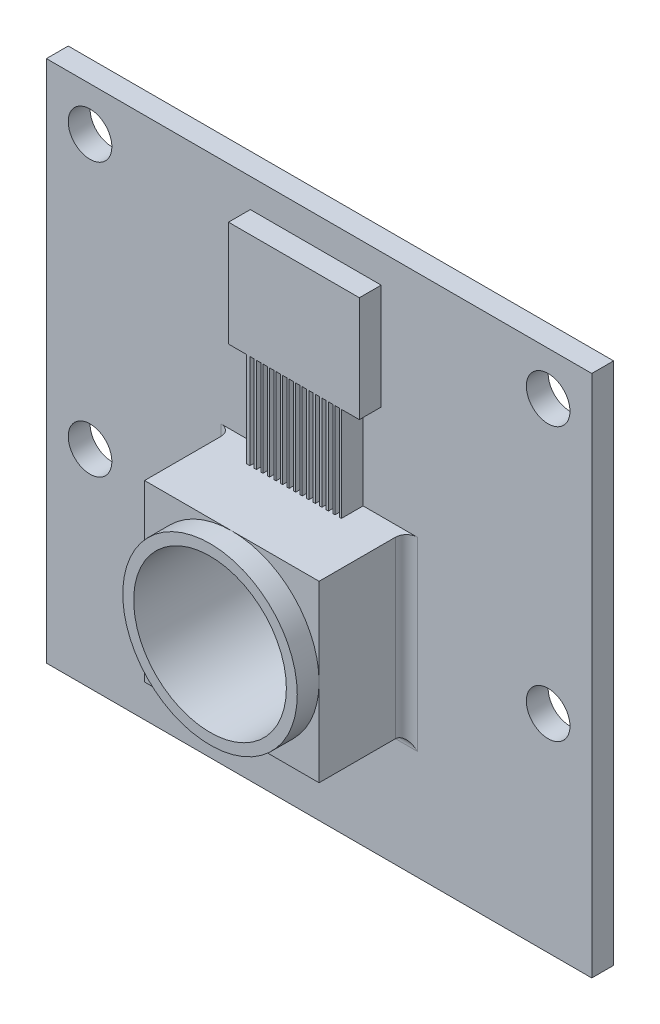
from build123d import *

# Parameters (mm, degrees)
SKETCH1_W           = 25
SKETCH1_H           = 24
SKETCH1_R           = 1
BOSS_EXTRUDE1_DEPTH = 1
SKETCH2_W           = 8
SKETCH2_H           = 8
BOSS_EXTRUDE2_DEPTH = 4
SKETCH3_R           = 4
BOSS_EXTRUDE3_DEPTH = 1
FILLET2_R           = 0.5
SKETCH4_W           = 16
SKETCH4_H           = 5
BOSS_EXTRUDE4_DEPTH = 2
FILLET3_R           = 0.5
SKETCH5_R           = 3.5
CUT_EXTRUDE1_DEPTH  = 6
BOSS_EXTRUDE5_DEPTH = 1
SKETCH7_W           = 0.2
SKETCH7_H           = 4.34
CUT_EXTRUDE2_DEPTH  = 1
LPATTERN1_COUNT     = 14
LPATTERN1_PITCH     = 0.3


with BuildPart() as part:
    # Sketch1 → Boss-Extrude1 (new body)
    with BuildSketch(Plane.XY):
        Rectangle(SKETCH1_W, SKETCH1_H)
        with Locations((10.5, 10)):
            Circle(SKETCH1_R, mode=Mode.SUBTRACT)
        with Locations((-10.5, 10)):
            Circle(SKETCH1_R, mode=Mode.SUBTRACT)
        with Locations((-10.5, -2.5)):
            Circle(SKETCH1_R, mode=Mode.SUBTRACT)
        with Locations((10.5, -2.5)):
            Circle(SKETCH1_R, mode=Mode.SUBTRACT)
    extrude(amount=BOSS_EXTRUDE1_DEPTH)

    # Sketch2 → Boss-Extrude2 (add)
    with BuildSketch(Plane.XY.offset(1)):
        with Locations((0, -2.5)):
            Rectangle(SKETCH2_W, SKETCH2_H)
    extrude(amount=BOSS_EXTRUDE2_DEPTH)

    # Sketch3 → Boss-Extrude3 (add)
    with BuildSketch(Plane.XY.offset(5)):
        with Locations((0, -2.5)):
            Circle(SKETCH3_R)
    extrude(amount=BOSS_EXTRUDE3_DEPTH)

    # Fillet2
    fillet2_edges = [part.edges().sort_by_distance(p)[0] for p in [
        (4, -2.5, 1),
        (-4, -2.5, 1),
        (0, -6.5, 1),
    ]]
    fillet(fillet2_edges, radius=FILLET2_R)

    # Sketch4 → Boss-Extrude4 (add)
    with BuildSketch(Plane(origin=(0, 0, 0), x_dir=(-1, 0, 0), z_dir=(0, 0, -1))):
        with Locations((0, -7.5)):
            Rectangle(SKETCH4_W, SKETCH4_H)
    extrude(amount=BOSS_EXTRUDE4_DEPTH)

    # Fillet3
    fillet3_edges = [part.edges().sort_by_distance(p)[0] for p in [
        (-8, -7.5, 0),
        (-8, -10, -1),
        (0, -5, 0),
        (-8, -5, -1),
        (8, -7.5, 0),
        (8, -5, -1),
        (0, -10, 0),
        (8, -10, -1),
        (-8, -7.5, -2),
        (0, -5, -2),
        (8, -7.5, -2),
        (0, -10, -2),
    ]]
    fillet(fillet3_edges, radius=FILLET3_R)

    # Sketch5 → Cut-Extrude1 (cut)
    with BuildSketch(Plane.XY.offset(6)):
        with Locations((0, -2.5)):
            Circle(SKETCH5_R)
    extrude(amount=-CUT_EXTRUDE1_DEPTH, mode=Mode.SUBTRACT)

    # Sketch6 → Boss-Extrude5 (add)
    with BuildSketch(Plane.XY.offset(1)):
        Polygon((-3.152517362, 10.68), (-3.152517362, 5.84), (-2.322578899, 5.84), (-2.322578899, 1.5), (2.017421101, 1.5), (2.017421101, 5.84), (2.846354447, 5.84), (2.846354447, 6.468877905), (2.846354447, 10.68), align=None)
    extrude(amount=BOSS_EXTRUDE5_DEPTH)

    # Sketch7 → Cut-Extrude2 (cut)
    with BuildSketch(Plane.XY.offset(2)):
        with Locations((-2.072578899, 3.67)):
            Rectangle(SKETCH7_W, SKETCH7_H)
    cut_extrude2 = extrude(amount=-CUT_EXTRUDE2_DEPTH, mode=Mode.SUBTRACT)

    # LPattern1: Cut-Extrude2 ×14
    with Locations(*[(i * LPATTERN1_PITCH, 0, 0) for i in range(1, LPATTERN1_COUNT)]):
        add(cut_extrude2, mode=Mode.SUBTRACT)


solid = part.part
